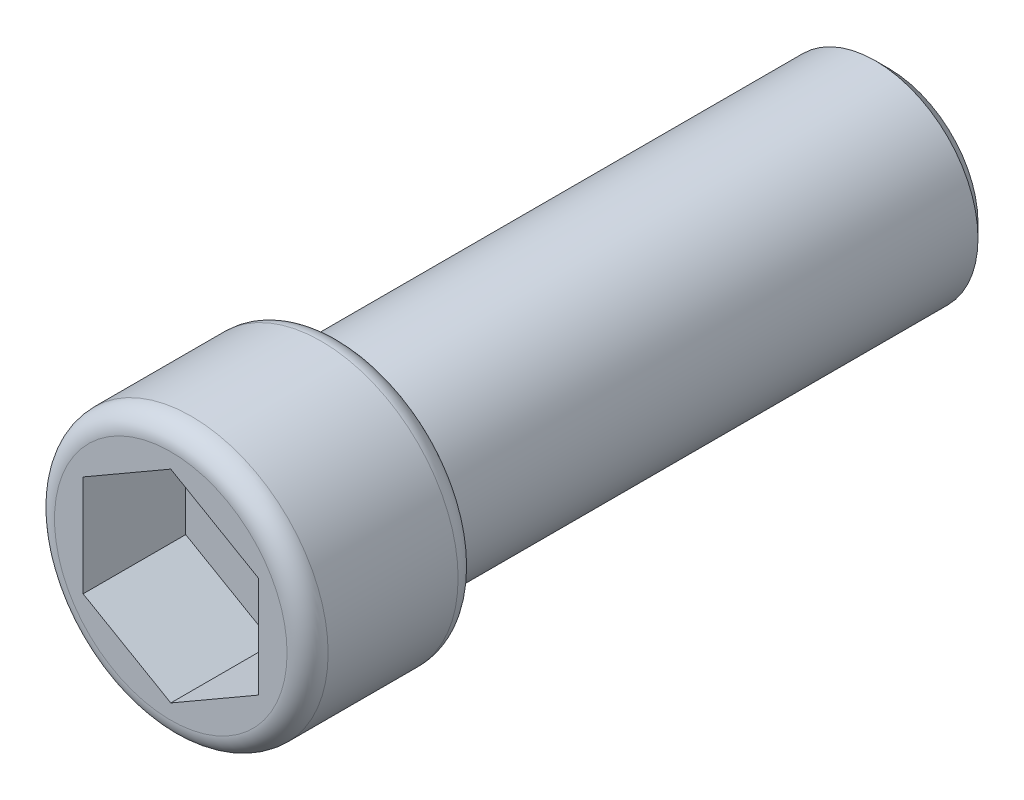
from build123d import *

# Parameters (mm, degrees)
SKETCH_1_R          = 1.5
EXTRUDE_1_DEPTH     = 8
SKETCH_2_R          = 2
EXTRUDE_2_DEPTH     = 2.5
CUT_EXTRUDE_1_DEPTH = 1.5
FILLET_1_R          = 0.3
CHAMFER_1_SIZE      = 0.2


with BuildPart() as part:
    # 草图1 → 凸台-拉伸1 (new body)
    with BuildSketch(Plane.XY):
        Circle(SKETCH_1_R)
    extrude(amount=EXTRUDE_1_DEPTH)

    # 草图2 → 凸台-拉伸2 (add)
    with BuildSketch(Plane.XY.offset(8)):
        Circle(SKETCH_2_R)
    extrude(amount=EXTRUDE_2_DEPTH)

    # 草图3 → 切除-拉伸1 (cut)
    with BuildSketch(Plane.XY.offset(10.5)):
        Polygon((0, 1.480060872), (-1.281770315, 0.740030436), (-1.281770315, -0.740030436), (0, -1.480060872), (1.281770315, -0.740030436), (1.281770315, 0.740030436), align=None)
    extrude(amount=-CUT_EXTRUDE_1_DEPTH, mode=Mode.SUBTRACT)

    # 圆角1
    fillet_1_edges = [part.edges().sort_by_distance(p)[0] for p in [
        (-2, 0, 8),
        (-2, 0, 10.5),
    ]]
    fillet(fillet_1_edges, radius=FILLET_1_R)

    # 倒角1
    chamfer_1_edges = [part.edges().sort_by_distance(p)[0] for p in [
        (-1.5, 0, 0),
    ]]
    chamfer(chamfer_1_edges, length=CHAMFER_1_SIZE)


solid = part.part
